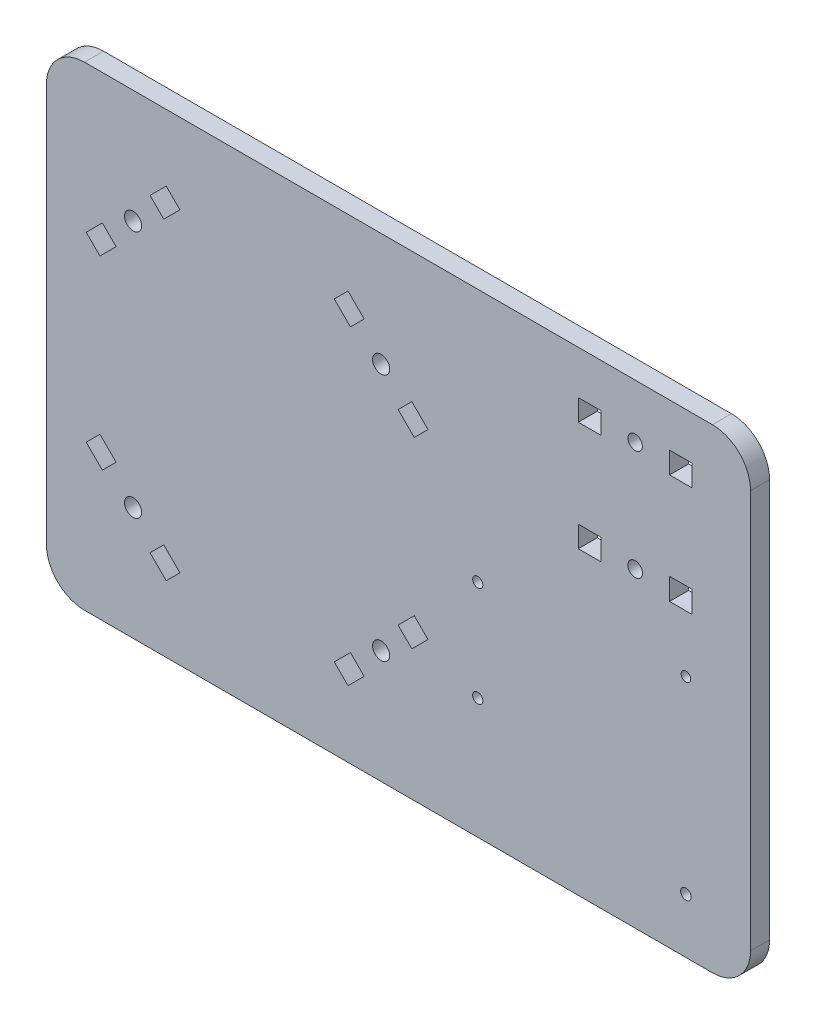
from build123d import *

# Parameters (mm, degrees)
SKETCH2_R           = 1.892615742
SKETCH2_R_2         = 1.931502603
SKETCH2_R_3         = 1.328987324
SKETCH2_R_4         = 1.256139718
SKETCH2_R_5         = 2.25
SKETCH2_R_6         = 1.346221639
SKETCH2_R_7         = 1.388588177
SKETCH2_W           = 5.927
SKETCH2_H           = 5.645543841
SKETCH2_H_2         = 5.614229543
SKETCH2_H_3         = 5.725940204
SKETCH2_H_4         = 5.592813932
BOSS_EXTRUDE3_DEPTH = 5


with BuildPart() as part:
    # Sketch2 → Boss-Extrude3 (new body)
    with BuildSketch(Plane.XY):
        with BuildLine():
            Line((185, -142.659400732), (185, -37.931368938))
            ThreePointArc((185, -37.931368938), (182.071067812, -30.860301126), (175, -27.931368938))
            Line((175, -27.931368938), (10, -27.931368938))
            ThreePointArc((10, -27.931368938), (2.928932188, -30.860301126), (0, -37.931368938))
            Line((0, -37.931368938), (0, -142.659400732))
            ThreePointArc((0, -142.659400732), (2.928932188, -149.730468544), (10, -152.659400732))
            Line((10, -152.659400732), (175, -152.659400732))
            ThreePointArc((175, -152.659400732), (182.071067812, -149.730468544), (185, -142.659400732))
        make_face()
        with Locations((154.694647781, -42.076845181)):
            Circle(SKETCH2_R, mode=Mode.SUBTRACT)
        with Locations((154.690357003, -70.942028449)):
            Circle(SKETCH2_R_2, mode=Mode.SUBTRACT)
        with Locations((113.33050486, -94.586932903)):
            Circle(SKETCH2_R_3, mode=Mode.SUBTRACT)
        with Locations((168.03050486, -88.730534378)):
            Circle(SKETCH2_R_4, mode=Mode.SUBTRACT)
        with Locations((22.757067444, -122.885983842)):
            Circle(SKETCH2_R_5, mode=Mode.SUBTRACT)
        with Locations((113.33050486, -120.963520008)):
            Circle(SKETCH2_R_6, mode=Mode.SUBTRACT)
        with Locations((168.03050486, -138.230534378)):
            Circle(SKETCH2_R_7, mode=Mode.SUBTRACT)
        with Locations((87.938265458, -122.885983842)):
            Circle(SKETCH2_R_5, mode=Mode.SUBTRACT)
        with Locations((87.938265458, -57.704785828)):
            Circle(SKETCH2_R_5, mode=Mode.SUBTRACT)
        with Locations((22.757067444, -57.704785828)):
            Circle(SKETCH2_R_5, mode=Mode.SUBTRACT)
        with Locations((166.691794259, -42.169597018)):
            Rectangle(SKETCH2_W, SKETCH2_H, mode=Mode.SUBTRACT)
        with Locations((142.703794259, -42.185254167)):
            Rectangle(SKETCH2_W, SKETCH2_H_2, mode=Mode.SUBTRACT)
        with Locations((166.691794259, -70.915398836)):
            Rectangle(SKETCH2_W, SKETCH2_H_3, mode=Mode.SUBTRACT)
        with Locations((142.703794259, -70.981961972)):
            Rectangle(SKETCH2_W, SKETCH2_H_4, mode=Mode.SUBTRACT)
        Polygon((10.446338383, -114.181499366), (14.68897907, -118.424140053), (18.295223654, -114.817895469), (14.052582967, -110.575254782), align=None, mode=Mode.SUBTRACT)
        Polygon((35.067796504, -131.590468319), (30.825155817, -127.347827632), (27.218911233, -130.954072216), (31.46155192, -135.196712903), align=None, mode=Mode.SUBTRACT)
        Polygon((96.642749934, -110.575254782), (92.400109247, -114.817895469), (96.006353831, -118.424140053), (100.248994518, -114.181499366), align=None, mode=Mode.SUBTRACT)
        Polygon((79.233780981, -135.196712903), (83.476421669, -130.954072216), (79.870177084, -127.347827632), (75.627536397, -131.590468319), align=None, mode=Mode.SUBTRACT)
        Polygon((75.627536397, -49.000301352), (79.870177084, -53.242942039), (83.476421669, -49.636697455), (79.233780981, -45.394056768), align=None, mode=Mode.SUBTRACT)
        Polygon((100.248994518, -66.409270305), (96.006353831, -62.166629618), (92.400109247, -65.772874202), (96.642749934, -70.015514889), align=None, mode=Mode.SUBTRACT)
        Polygon((31.46155192, -45.394056768), (27.218911233, -49.636697455), (30.825155817, -53.242942039), (35.067796504, -49.000301352), align=None, mode=Mode.SUBTRACT)
        Polygon((14.052582967, -70.015514889), (18.295223654, -65.772874202), (14.68897907, -62.166629618), (10.446338383, -66.409270305), align=None, mode=Mode.SUBTRACT)
    extrude(amount=BOSS_EXTRUDE3_DEPTH)


solid = part.part
